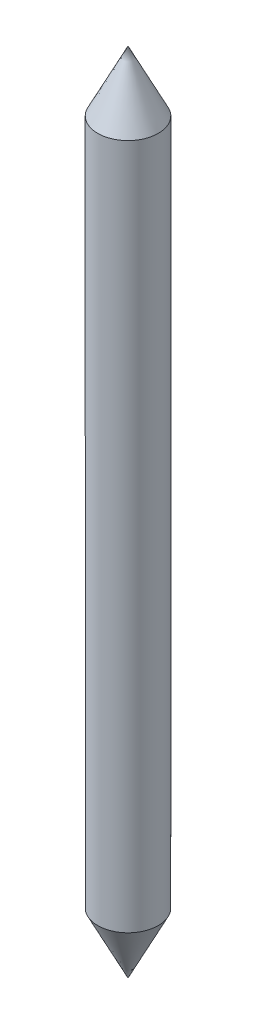
from build123d import *


with BuildPart() as part:
    # Croquis1 → Revolución1 (revolve)
    with BuildSketch(Plane.XY):
        Polygon((-1.868695092, 16.706266518), (-1.493695092, 17.456266518), (-1.493695092, 25.956266518), (-1.868695092, 26.706266518), align=None)
    revolve(axis=Axis((-1.868695092, 16.706266518, 0), (0, 1, 0)))


solid = part.part
